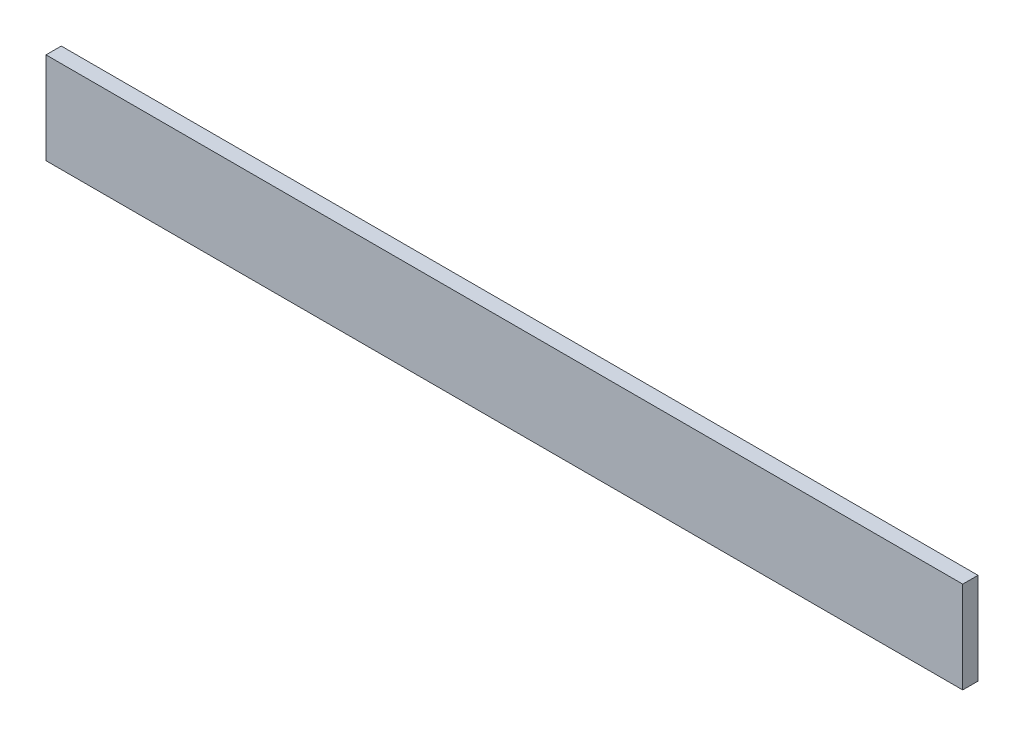
from build123d import *

# Parameters (mm, degrees)
SKETCH1_W           = 300
SKETCH1_H           = 30
BOSS_EXTRUDE1_DEPTH = 5


with BuildPart() as part:
    # Sketch1 → Boss-Extrude1 (new body)
    with BuildSketch(Plane.XY):
        with Locations((150, 15)):
            Rectangle(SKETCH1_W, SKETCH1_H)
    extrude(amount=BOSS_EXTRUDE1_DEPTH)


solid = part.part
